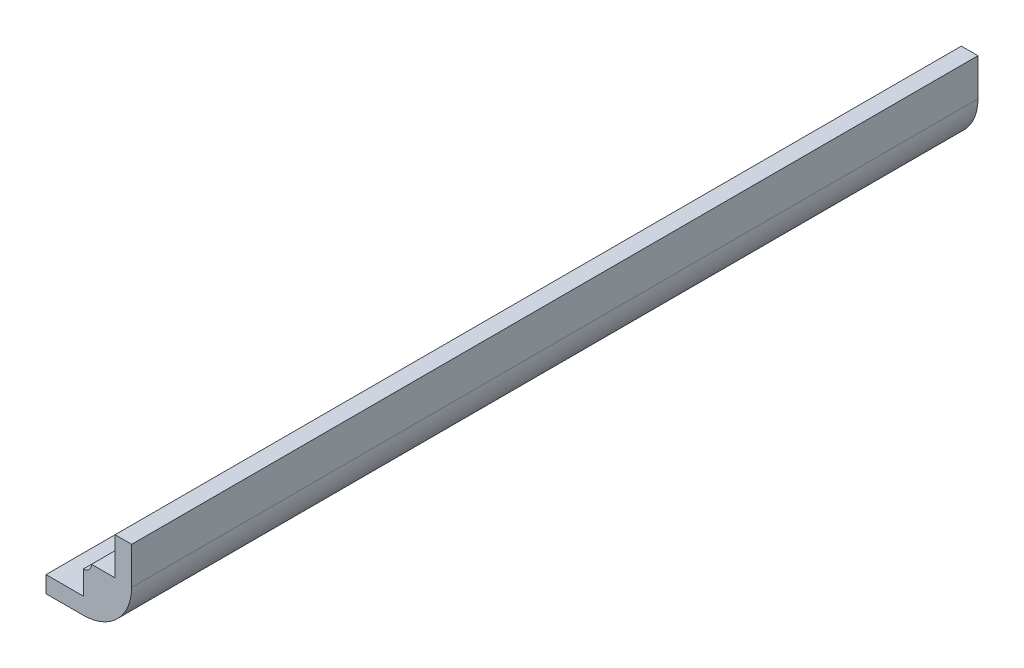
from build123d import *

# Parameters (mm, degrees)
SKETCH7_W           = 4.7625
SKETCH7_H           = 2.12122512
BOSS_EXTRUDE2_DEPTH = 53.975
SKETCH8_W           = 2.12122512
SKETCH8_H           = 4.7625
BOSS_EXTRUDE3_DEPTH = 53.975
BOSS_EXTRUDE4_DEPTH = 53.975


with BuildPart() as part:
    # Sketch7 → Boss-Extrude2 (new, symmetric)
    with BuildSketch(Plane.XY):
        with Locations((-4.92125, -2.560612608)):
            Rectangle(SKETCH7_W, SKETCH7_H)
    extrude(amount=BOSS_EXTRUDE2_DEPTH, both=True)



with BuildPart() as body_2:
    # Sketch8 → Boss-Extrude3 (new, symmetric)
    with BuildSketch(Plane.XY):
        with Locations((2.560612608, 4.92125)):
            Rectangle(SKETCH8_W, SKETCH8_H)
    extrude(amount=BOSS_EXTRUDE3_DEPTH, both=True)


with BuildPart() as part_1:
    add(part.part)

    add(body_2.part)  # Boss-Extrude4 merges body 2
    # Sketch11 → Boss-Extrude4 (add, symmetric)
    with BuildSketch(Plane.XY):
        with BuildLine():
            Line((-2.54, -1.500000048), (-7.3025, -1.500000048))
            Line((-7.3025, -1.500000048), (-7.3025, -3.621225168))
            Line((-7.3025, -3.621225168), (-2.54, -3.621225168))
            ThreePointArc((-2.54, -3.621225168), (1.816644097, -1.816644097), (3.621225168, 2.54))
            Line((3.621225168, 2.54), (3.621225168, 7.3025))
            Line((3.621225168, 7.3025), (1.500000048, 7.3025))
            Line((1.500000048, 7.3025), (1.500000048, 2.54))
            Line((1.500000048, 2.54), (-1.500000048, 2.54))
            ThreePointArc((-1.500000048, 2.54), (-1.804608982, 1.804608982), (-2.54, 1.500000048))
            Line((-2.54, 1.500000048), (-2.54, -1.500000048))
        make_face()
    extrude(amount=BOSS_EXTRUDE4_DEPTH, both=True)


solid = part_1.part
